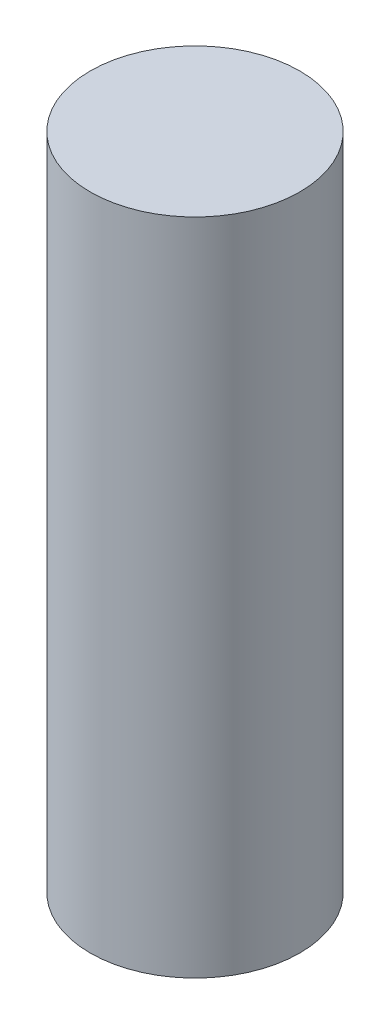
from build123d import *

# Parameters (mm, degrees)
SKETCH1_R           = 1.59
BOSS_EXTRUDE1_DEPTH = 10


with BuildPart() as part:
    # Sketch1 → Boss-Extrude1 (new body)
    with BuildSketch(Plane(origin=(0, 0, 0), x_dir=(1, 0, 0), z_dir=(0, 1, 0))):
        Circle(SKETCH1_R)
    extrude(amount=BOSS_EXTRUDE1_DEPTH)


solid = part.part
